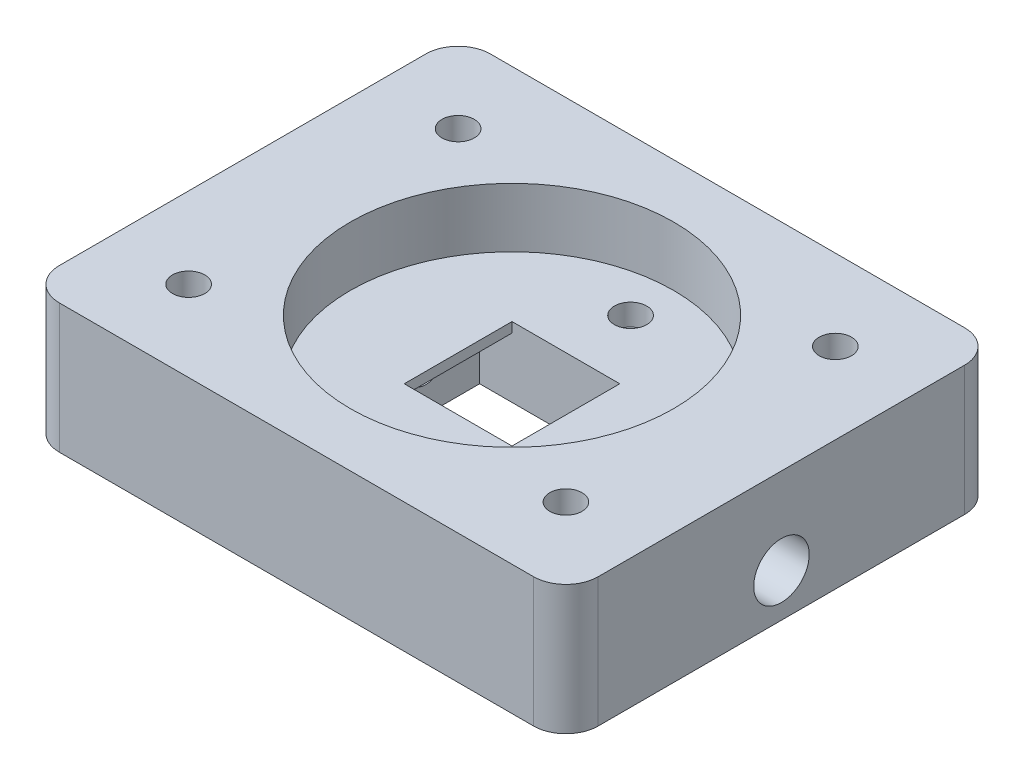
from build123d import *

# Parameters (mm, degrees)
SKETCH1_W            = 50
SKETCH1_H            = 40
BODY_DEPTH           = 12
FILLETBODY_R         = 3
SKETCH41_R           = 1.575
CHANNEL1_DEPTH       = 57
SKETCH42_R           = 2.575
INLET_DEPTH          = 5
SKETCH43_R           = 2.575
OUTLET_DEPTH         = 5
SKETCH44_R           = 15
WINDOW_DEPTH         = 5.5
SKETCH45_W           = 16
SKETCH45_H           = 10
FLOWCH_DEPTH         = 5.575
SKETCH46_W           = 10
SKETCH46_H           = 10
WINDOW_HOLE_DEPTH    = 16
SKETCH49_R           = 1.5
FIXHOLES_DEPTH       = 2
GASKET_DEPTH         = 1
SKETCH3_R            = 1.5
BOLT_HOLE_DEPTH      = 10
BOLT_HOLE_DEPTH_BACK = 31


with BuildPart() as part:
    # Sketch1 → Body (new body)
    with BuildSketch(Plane(origin=(0, 0, 0), x_dir=(1, 0, 0), z_dir=(0, 1, 0))):
        Rectangle(SKETCH1_W, SKETCH1_H)
    extrude(amount=BODY_DEPTH)

    # FilletBody
    filletbody_edges = [part.edges().sort_by_distance(p)[0] for p in [
        (-25, 6, -20),
        (25, 6, -20),
        (25, 6, 20),
        (-25, 6, 20),
    ]]
    fillet(filletbody_edges, radius=FILLETBODY_R)

    # Sketch41 → Channel1 (cut)
    with BuildSketch(Plane.ZY.offset(25)):
        with Locations((0, 4)):
            Circle(SKETCH41_R)
    extrude(amount=-CHANNEL1_DEPTH, mode=Mode.SUBTRACT)

    # Sketch42 → Inlet (cut)
    with BuildSketch(Plane.ZY.offset(25)):
        with Locations((0, 4)):
            Circle(SKETCH42_R)
    extrude(amount=-INLET_DEPTH, mode=Mode.SUBTRACT)

    # Sketch43 → Outlet (cut)
    with BuildSketch(Plane(origin=(25, 0, 0), x_dir=(0, 0, -1), z_dir=(1, 0, 0))):
        with Locations((0, 4)):
            Circle(SKETCH43_R)
    extrude(amount=-OUTLET_DEPTH, mode=Mode.SUBTRACT)

    # Sketch44 → Window (cut)
    with BuildSketch(Plane(origin=(0, 12, 0), x_dir=(1, 0, 0), z_dir=(0, 1, 0))):
        Circle(SKETCH44_R)
    extrude(amount=-WINDOW_DEPTH, mode=Mode.SUBTRACT)

    # Sketch45 → FlowCh (cut)
    with BuildSketch(Plane.XZ):
        Rectangle(SKETCH45_W, SKETCH45_H)
    extrude(amount=-FLOWCH_DEPTH, mode=Mode.SUBTRACT)

    # Sketch46 → Window_hole (cut)
    with BuildSketch(Plane(origin=(0, 6.5, 0), x_dir=(1, 0, 0), z_dir=(0, 1, 0))):
        Rectangle(SKETCH46_W, SKETCH46_H)
    extrude(amount=-WINDOW_HOLE_DEPTH, mode=Mode.SUBTRACT)

    # Sketch49 → FixHoles (cut)
    with BuildSketch(Plane(origin=(0, 6.5, 0), x_dir=(1, 0, 0), z_dir=(0, 1, 0))):
        with Locations((0, 11)):
            Circle(SKETCH49_R)
        with Locations((0, -11)):
            Circle(SKETCH49_R)
    extrude(amount=-FIXHOLES_DEPTH, mode=Mode.SUBTRACT)

    # Sketch50 → Gasket (cut)
    with BuildSketch(Plane.XZ):
        with BuildLine():
            ThreePointArc((8, 11), (12.242640687, 9.242640687), (14, 5))
            Line((14, 5), (14, -5))
            ThreePointArc((14, -5), (12.242640687, -9.242640687), (8, -11))
            Line((8, -11), (-8, -11))
            ThreePointArc((-8, -11), (-12.242640687, -9.242640687), (-14, -5))
            Line((-14, -5), (-14, 5))
            ThreePointArc((-14, 5), (-12.242640687, 9.242640687), (-8, 11))
            Line((-8, 11), (8, 11))
        make_face()
        with BuildLine():
            Line((-8, -7), (8, -7))
            ThreePointArc((8, -7), (9.414213562, -6.414213562), (10, -5))
            Line((10, -5), (10, 5))
            ThreePointArc((10, 5), (9.414213562, 6.414213562), (8, 7))
            Line((8, 7), (-8, 7))
            ThreePointArc((-8, 7), (-9.414213562, 6.414213562), (-10, 5))
            Line((-10, 5), (-10, -5))
            ThreePointArc((-10, -5), (-9.414213562, -6.414213562), (-8, -7))
        make_face(mode=Mode.SUBTRACT)
    extrude(amount=-GASKET_DEPTH, mode=Mode.SUBTRACT)

    # Sketch3 → Bolt_hole (cut, two sides)
    with BuildSketch(Plane(origin=(0, 12, 0), x_dir=(1, 0, 0), z_dir=(0, 1, 0))) as bolt_hole_sk:
        with Locations((-17.5, 12.5)):
            Circle(SKETCH3_R)
        with Locations((17.5, 12.5)):
            Circle(SKETCH3_R)
        with Locations((17.5, -12.5)):
            Circle(SKETCH3_R)
        with Locations((-17.5, -12.5)):
            Circle(SKETCH3_R)
    extrude(amount=BOLT_HOLE_DEPTH, mode=Mode.SUBTRACT)
    extrude(bolt_hole_sk.sketch, amount=-BOLT_HOLE_DEPTH_BACK, mode=Mode.SUBTRACT)


solid = part.part
